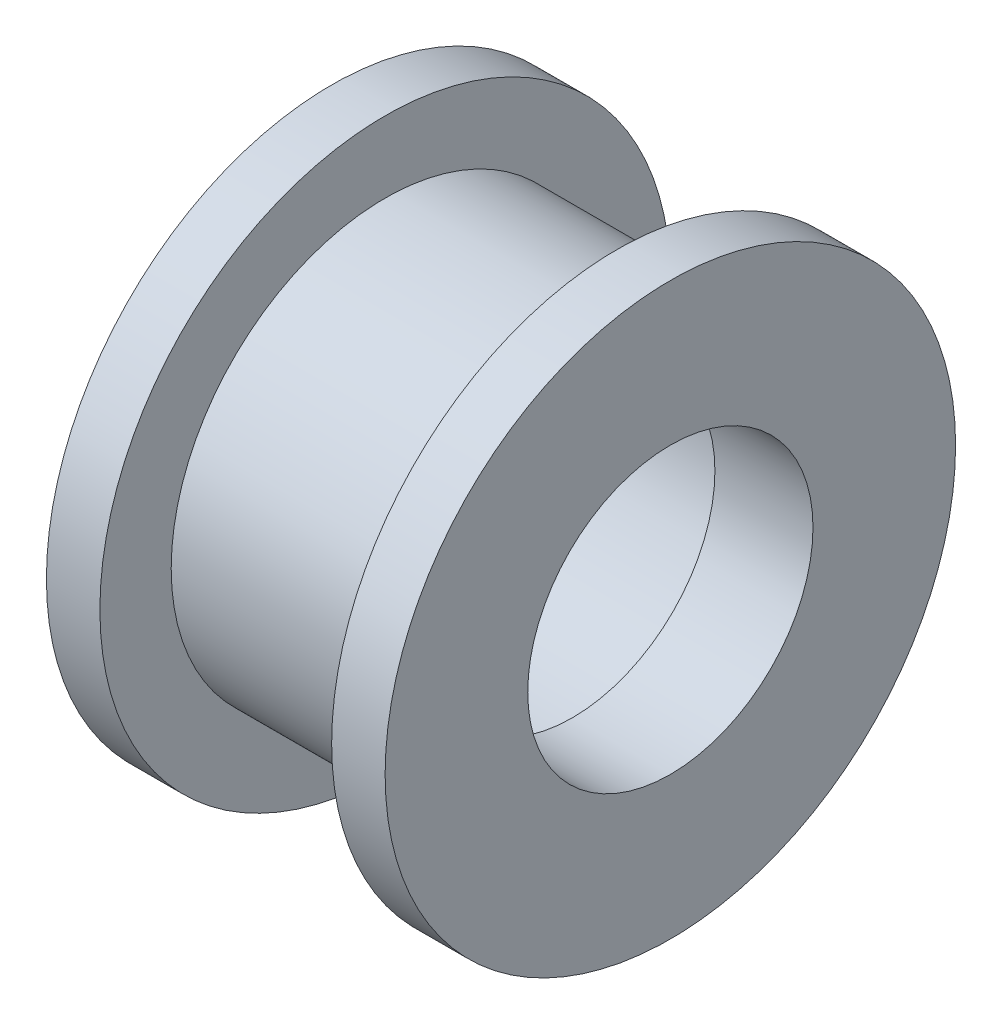
from build123d import *


with BuildPart() as part:
    # Esquisse2 → Révolution1 (revolve)
    with BuildSketch(Plane.XY):
        Polygon((-5.5, 4.975), (1.25, 4.975), (1.25, 4), (4, 4), (4, 8), (2.5, 8), (2.5, 6), (-4, 6), (-4, 8), (-5.5, 8), align=None)
    revolve(axis=Axis((-17.303448276, 0, 0), (1, 0, 0)))


solid = part.part
